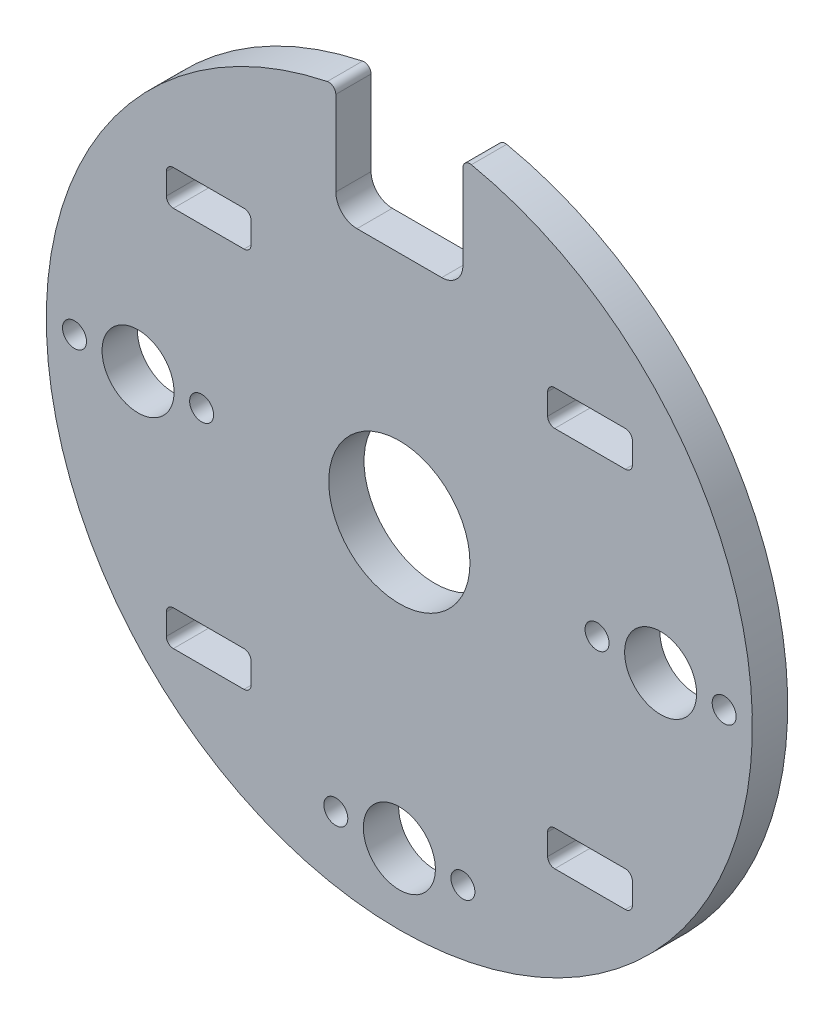
from build123d import *

# Parameters (mm, degrees)
SKETCH1_R                    = 50
BOSS_EXTRUDE1_DEPTH          = 5
F_10_2_10_2_DIAMETER_HOLE1_D = 10.2
M3_CLEARANCE_HOLE1_D         = 3.4
CUT_EXTRUDE2_DEPTH           = 5
CUT_EXTRUDE3_DEPTH           = 10
FILLET1_R                    = 1
SKETCH13_R                   = 10
CUT_EXTRUDE4_DEPTH           = 10


with BuildPart() as part:
    # Sketch1 → Boss-Extrude1 (new body)
    with BuildSketch(Plane.XY):
        Circle(SKETCH1_R)
    extrude(amount=BOSS_EXTRUDE1_DEPTH)

    # Ø10.2 (10.2) Diameter Hole1 (through all)
    with Locations(Plane(origin=(0, 0, 0), x_dir=(-1, 0, 0), z_dir=(0, 0, -1))):
        with Locations((37, 0), (-37, 0), (0, -40)):
            Hole(F_10_2_10_2_DIAMETER_HOLE1_D / 2)

    # M3 Clearance Hole1 (through all)
    with Locations(Plane.XY.offset(5)):
        with Locations((46, 0), (28, 0), (9, -40), (-9, -40), (-46, 0), (-28, 0)):
            Hole(M3_CLEARANCE_HOLE1_D / 2)

    # Sketch11 → Cut-Extrude2 (cut)
    with BuildSketch(Plane.XY.offset(5)):
        with BuildLine():
            Line((22, 22.5), (32, 22.5))
            ThreePointArc((32, 22.5), (32.707106781, 22.792893219), (33, 23.5))
            Line((33, 23.5), (33, 26.5))
            ThreePointArc((33, 26.5), (32.707106781, 27.207106781), (32, 27.5))
            Line((32, 27.5), (22, 27.5))
            ThreePointArc((22, 27.5), (21.292893219, 27.207106781), (21, 26.5))
            Line((21, 26.5), (21, 23.5))
            ThreePointArc((21, 23.5), (21.292893219, 22.792893219), (22, 22.5))
        make_face()
        with BuildLine():
            Line((-22, 27.5), (-32, 27.5))
            ThreePointArc((-32, 27.5), (-32.707106781, 27.207106781), (-33, 26.5))
            Line((-33, 26.5), (-33, 23.5))
            ThreePointArc((-33, 23.5), (-32.707106781, 22.792893219), (-32, 22.5))
            Line((-32, 22.5), (-22, 22.5))
            ThreePointArc((-22, 22.5), (-21.292893219, 22.792893219), (-21, 23.5))
            Line((-21, 23.5), (-21, 26.5))
            ThreePointArc((-21, 26.5), (-21.292893219, 27.207106781), (-22, 27.5))
        make_face()
        with BuildLine():
            Line((-21, -27.5), (-21, -30.5))
            ThreePointArc((-21, -30.5), (-21.292893219, -31.207106781), (-22, -31.5))
            Line((-22, -31.5), (-32, -31.5))
            ThreePointArc((-32, -31.5), (-32.707106781, -31.207106781), (-33, -30.5))
            Line((-33, -30.5), (-33, -27.5))
            ThreePointArc((-33, -27.5), (-32.707106781, -26.792893219), (-32, -26.5))
            Line((-32, -26.5), (-22, -26.5))
            ThreePointArc((-22, -26.5), (-21.292893219, -26.792893219), (-21, -27.5))
        make_face()
        with BuildLine():
            Line((22, -31.5), (32, -31.5))
            ThreePointArc((32, -31.5), (32.707106781, -31.207106781), (33, -30.5))
            Line((33, -30.5), (33, -27.5))
            ThreePointArc((33, -27.5), (32.707106781, -26.792893219), (32, -26.5))
            Line((32, -26.5), (22, -26.5))
            ThreePointArc((22, -26.5), (21.292893219, -26.792893219), (21, -27.5))
            Line((21, -27.5), (21, -30.5))
            ThreePointArc((21, -30.5), (21.292893219, -31.207106781), (22, -31.5))
        make_face()
    extrude(amount=-CUT_EXTRUDE2_DEPTH, mode=Mode.SUBTRACT)

    # Sketch12 → Cut-Extrude3 (cut)
    with BuildSketch(Plane.XY.offset(5)):
        with BuildLine():
            Line((-6, 33), (6, 33))
            ThreePointArc((6, 33), (8.121320344, 33.878679656), (9, 36))
            Line((9, 36), (9, 50))
            Line((9, 50), (-9, 50))
            Line((-9, 50), (-9, 36))
            ThreePointArc((-9, 36), (-8.121320344, 33.878679656), (-6, 33))
        make_face()
    extrude(amount=-CUT_EXTRUDE3_DEPTH, mode=Mode.SUBTRACT)

    # Fillet1
    fillet1_edges = [part.edges().sort_by_distance(p)[0] for p in [
        (-9, 49.183330509, 2.5),
        (9, 49.183330509, 2.5),
    ]]
    fillet(fillet1_edges, radius=FILLET1_R)

    # Sketch13 → Cut-Extrude4 (cut)
    with BuildSketch(Plane.XY.offset(5)):
        Circle(SKETCH13_R)
    extrude(amount=-CUT_EXTRUDE4_DEPTH, mode=Mode.SUBTRACT)


solid = part.part
